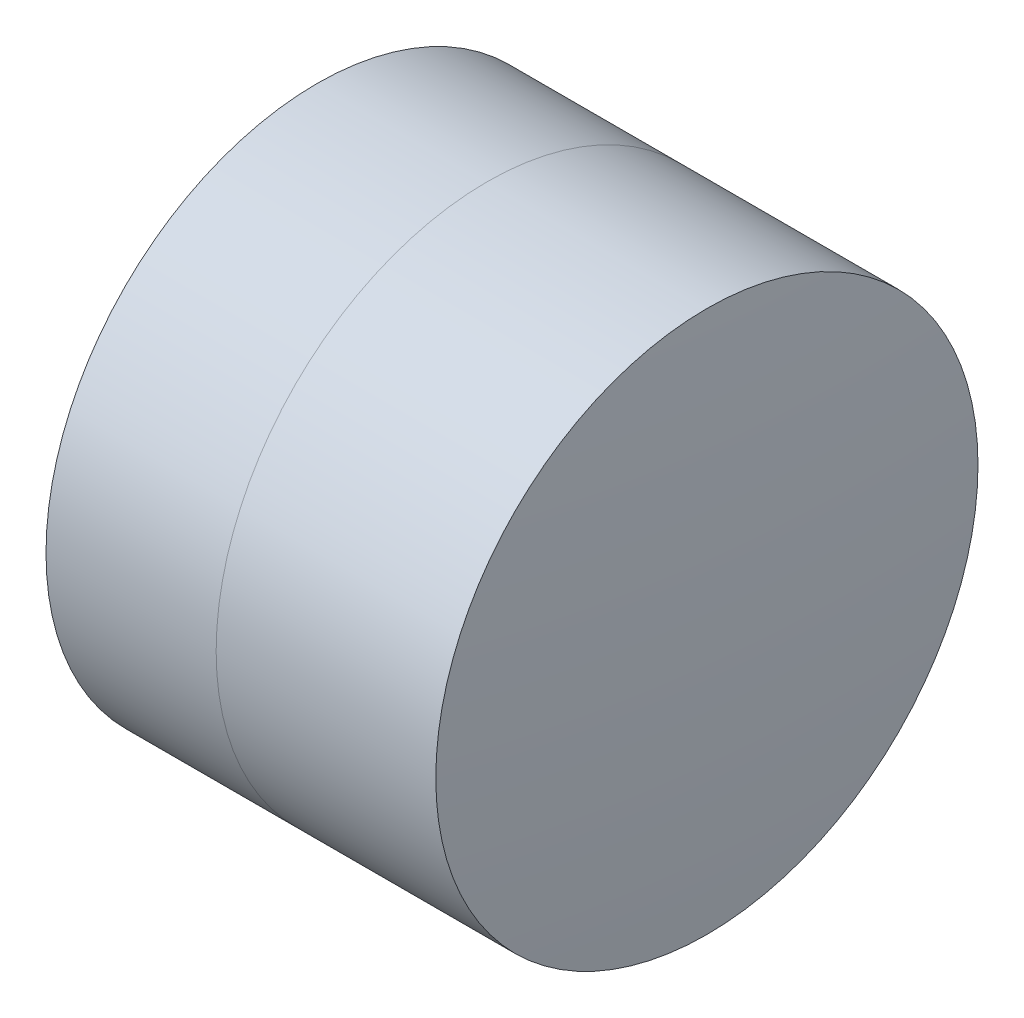
from build123d import *


with BuildPart() as part:
    # 草图1 one side → 旋转1 (revolve)
    with BuildSketch(Plane(origin=(0, 0, 0), x_dir=(1, 0, 0), z_dir=(0, 1, 0)), mode=Mode.PRIVATE) as revolve_1_sk:
        with BuildLine():
            ThreePointArc((261.240152261, 2.5), (261.009439852, 1.25945087), (260.932149058, 0))
            Line((260.932149058, 0), (263.232149058, 0))
            ThreePointArc((263.232149058, 0), (263.125664764, 1.26776274), (262.809195804, 2.5))
            Line((262.809195804, 2.5), (261.240152261, 2.5))
        make_face()
    revolve(revolve_1_sk.sketch.rotate(Axis((124.523309526, 0, 0), (1, 0, 0)), 180), axis=Axis((124.523309526, 0, 0), (1, 0, 0)))  # turned: the seam where the file's is


with BuildPart() as body_2:
    # 草图2 one side → 旋转3 (revolve)
    with BuildSketch(Plane(origin=(0, 0, 0), x_dir=(1, 0, 0), z_dir=(0, 1, 0)), mode=Mode.PRIVATE) as revolve_3_sk:
        with BuildLine():
            Line((264.83464896, 2.5), (262.809195804, 2.5))
            ThreePointArc((262.809195804, 2.5), (263.125664764, 1.26776274), (263.232149058, 0))
            Line((263.232149058, 0), (264.932149058, 0))
            ThreePointArc((264.932149058, 0), (264.907764772, 1.250950266), (264.83464896, 2.5))
        make_face()
    revolve(revolve_3_sk.sketch.rotate(Axis((-0.551919993, 0, 0), (1, 0, 0)), 180), axis=Axis((-0.551919993, 0, 0), (1, 0, 0)))  # turned: the seam where the file's is


solid = Compound([part.part, body_2.part])
